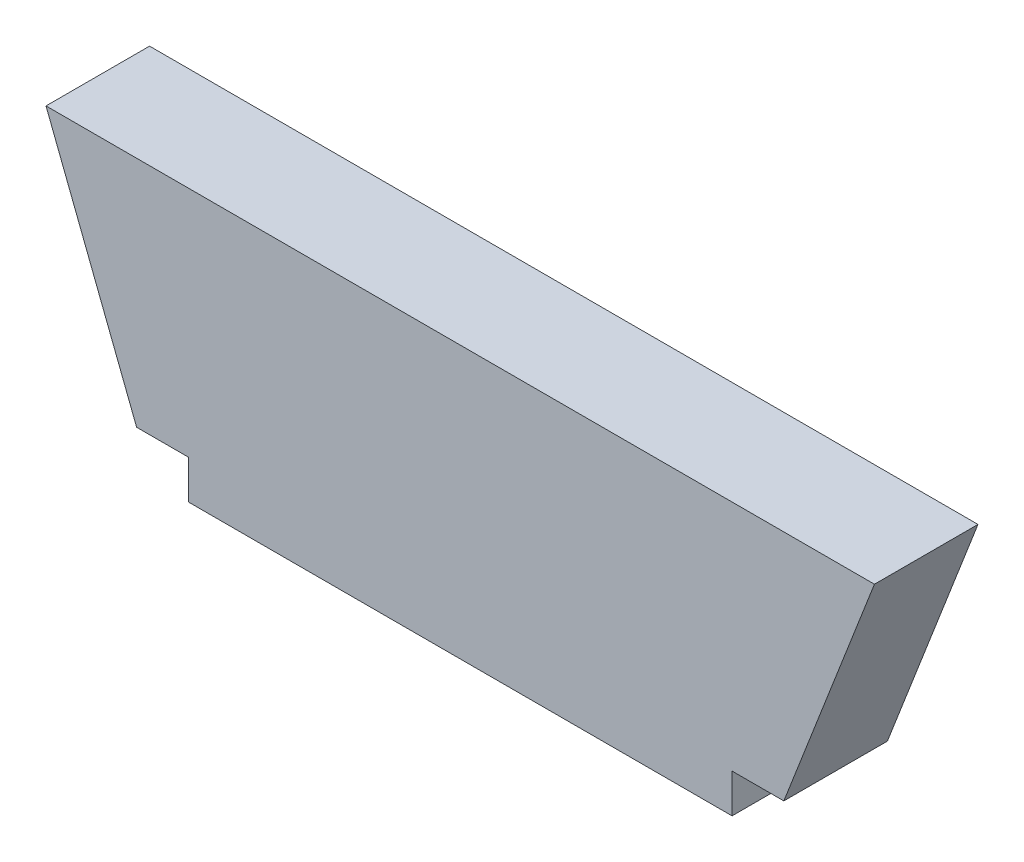
from build123d import *

# Parameters (mm, degrees)
EXTRUDE_1_DEPTH = 8


with BuildPart() as part:
    # Эскиз1 → Бобышка-Вытянуть1 (new body)
    with BuildSketch(Plane.XY):
        Polygon((-32, 18), (32, 18), (25, 0), (21, 0), (21, -3), (-21, -3), (-21, 0), (-25, 0), align=None)
    extrude(amount=EXTRUDE_1_DEPTH)


solid = part.part
